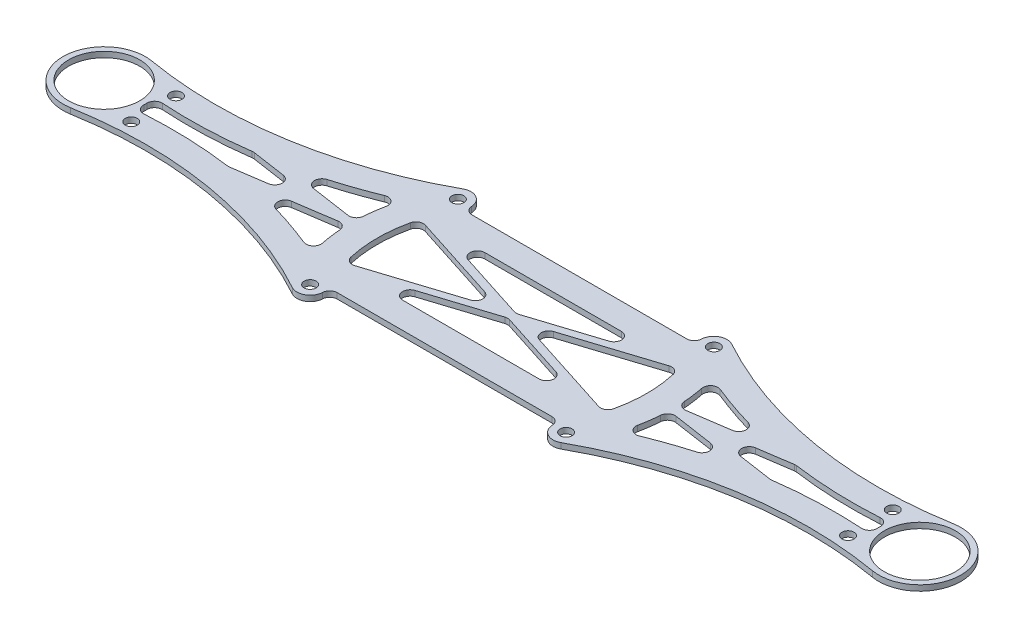
from build123d import *

# Parameters (mm, degrees)
SKETCH1_R                  = 3.5
BOSS_EXTRUDE1_DEPTH        = 0.75
F_3_2_3_2_DIAMETER_HOLE1_D = 3.2
SKETCH4_R                  = 9.5
CUT_EXTRUDE1_DEPTH         = 2.5
CUT_EXTRUDE4_DEPTH         = 2.5
FILLET1_R                  = 2


with BuildPart() as part:
    # Sketch1 → Boss-Extrude1 (new body, symmetric)
    with BuildSketch(Plane(origin=(0, 0, 0), x_dir=(1, 0, 0), z_dir=(0, 1, 0))):
        with BuildLine():
            ThreePointArc((-37.239092363, -21.5), (-43, 0), (-37.239092363, 21.5))
            ThreePointArc((-37.239092363, 21.5), (-36.658838331, 22.248681329), (-35.899079455, 22.81435343))
            ThreePointArc((-35.899079455, 22.81435343), (-70.492179883, 10.7556392), (-107.126701642, 10.839315166))
            ThreePointArc((-107.126701642, 10.839315166), (-120, 0), (-107.126701642, -10.839315166))
            ThreePointArc((-107.126701642, -10.839315166), (-70.492179883, -10.7556392), (-35.899079455, -22.81435343))
            ThreePointArc((-35.899079455, -22.81435343), (-36.658838331, -22.248681329), (-37.239092363, -21.5))
        make_face()
        with BuildLine():
            ThreePointArc((-31.176914536, -18), (-36, 0), (-31.176914536, 18))
            ThreePointArc((-31.176914536, 18), (-35.958003449, 16.718911087), (-37.239092363, 21.5))
            ThreePointArc((-37.239092363, 21.5), (-43, 0), (-37.239092363, -21.5))
            ThreePointArc((-37.239092363, -21.5), (-35.958003449, -16.718911087), (-31.176914536, -18))
        make_face()
        with Locations((-34.208003449, -19.75)):
            Circle(SKETCH1_R)
        with Locations((-34.208003449, 19.75)):
            Circle(SKETCH1_R)
        with BuildLine():
            ThreePointArc((31.176914536, 18), (36, 0), (31.176914536, -18))
            Line((31.176914536, -18), (-31.176914536, -18))
            ThreePointArc((-31.176914536, -18), (-36, 0), (-31.176914536, 18))
            Line((-31.176914536, 18), (31.176914536, 18))
        make_face()
        with Locations((34.208003449, 19.75)):
            Circle(SKETCH1_R)
        with BuildLine():
            ThreePointArc((37.708003449, 19.75), (35.113870107, 16.369259608), (31.176914536, 18))
            ThreePointArc((31.176914536, 18), (36, 0), (31.176914536, -18))
            ThreePointArc((31.176914536, -18), (35.113870107, -16.369259608), (37.708003449, -19.75))
            ThreePointArc((37.708003449, -19.75), (37.588743841, -20.655866658), (37.239092363, -21.5))
            ThreePointArc((37.239092363, -21.5), (43, 0), (37.239092363, 21.5))
            ThreePointArc((37.239092363, 21.5), (37.588743841, 20.655866658), (37.708003449, 19.75))
        make_face()
        with Locations((34.208003449, -19.75)):
            Circle(SKETCH1_R)
        with BuildLine():
            ThreePointArc((107.126701642, 10.839315166), (70.492179883, 10.7556392), (35.899079455, 22.81435343))
            ThreePointArc((35.899079455, 22.81435343), (36.658838331, 22.248681329), (37.239092363, 21.5))
            ThreePointArc((37.239092363, 21.5), (43, 0), (37.239092363, -21.5))
            ThreePointArc((37.239092363, -21.5), (36.658838331, -22.248681329), (35.899079455, -22.81435343))
            ThreePointArc((35.899079455, -22.81435343), (70.492179883, -10.7556392), (107.126701642, -10.839315166))
            ThreePointArc((107.126701642, -10.839315166), (120, 0), (107.126701642, 10.839315166))
        make_face()
    extrude(amount=BOSS_EXTRUDE1_DEPTH, both=True)

    # Ø3.2 (3.2) Diameter Hole1 (through all)
    with Locations(Plane(origin=(0, 0.75, 0), x_dir=(1, 0, 0), z_dir=(0, 1, 0))):
        with Locations((-34.208003449, 19.75), (-34.208003449, -19.75), (34.208003449, -19.75), (34.208003449, 19.75), (-95.790276336, 5.979398024), (-95.790276336, -5.979398024), (95.790276336, 5.979398024), (95.790276336, -5.979398024)):
            Hole(F_3_2_3_2_DIAMETER_HOLE1_D / 2)

    # Sketch4 → Cut-Extrude1 (cut, through all)
    with BuildSketch(Plane(origin=(0, 0.75, 0), x_dir=(1, 0, 0), z_dir=(0, 1, 0))):
        with Locations((-109, 0)):
            Circle(SKETCH4_R)
        with BuildLine():
            Line((-72.469338063, -3.369046694), (-49.802019621, 0))
            Line((-49.802019621, 0), (-72.469338063, 3.369046694))
            ThreePointArc((-72.469338063, 3.369046694), (-85.377857375, 2.290839769), (-98.326107181, 2.65857332))
            ThreePointArc((-98.326107181, 2.65857332), (-98, 0), (-98.326107181, -2.65857332))
            ThreePointArc((-98.326107181, -2.65857332), (-85.377857375, -2.290839769), (-72.469338063, -3.369046694))
        make_face()
        with BuildLine():
            Line((-66.096117167, 4.443764231), (-42.988154947, 1.009224591))
            ThreePointArc((-42.988154947, 1.009224591), (-42.467311238, 6.747405149), (-41.183985346, 12.36443897))
            ThreePointArc((-41.183985346, 12.36443897), (-53.416219701, 7.70010587), (-66.096117167, 4.443764231))
        make_face()
        with BuildLine():
            ThreePointArc((-41.183985346, -12.36443897), (-42.467311238, -6.747405149), (-42.988154947, -1.009224591))
            Line((-42.988154947, -1.009224591), (-66.096117167, -4.443764231))
            ThreePointArc((-66.096117167, -4.443764231), (-53.416219701, -7.70010587), (-41.183985346, -12.36443897))
        make_face()
        with BuildLine():
            Line((72.469338063, 3.369046694), (49.802019621, 0))
            Line((49.802019621, 0), (72.469338063, -3.369046694))
            ThreePointArc((72.469338063, -3.369046694), (85.377857375, -2.290839769), (98.326107181, -2.65857332))
            ThreePointArc((98.326107181, -2.65857332), (98, 0), (98.326107181, 2.65857332))
            ThreePointArc((98.326107181, 2.65857332), (85.377857375, 2.290839769), (72.469338063, 3.369046694))
        make_face()
        with BuildLine():
            ThreePointArc((41.183985346, 12.36443897), (42.467311238, 6.747405149), (42.988154947, 1.009224591))
            Line((42.988154947, 1.009224591), (66.096117167, 4.443764231))
            ThreePointArc((66.096117167, 4.443764231), (53.416219701, 7.70010587), (41.183985346, 12.36443897))
        make_face()
        with BuildLine():
            Line((66.096117167, -4.443764231), (42.988154947, -1.009224591))
            ThreePointArc((42.988154947, -1.009224591), (42.467311238, -6.747405149), (41.183985346, -12.36443897))
            ThreePointArc((41.183985346, -12.36443897), (53.416219701, -7.70010587), (66.096117167, -4.443764231))
        make_face()
        with Locations((109, 0)):
            Circle(SKETCH4_R)
    extrude(amount=-CUT_EXTRUDE1_DEPTH, mode=Mode.SUBTRACT)

    # Sketch5 → Cut-Extrude4 (cut, through all)
    with BuildSketch(Plane(origin=(0, 0.75, 0), x_dir=(1, 0, 0), z_dir=(0, 1, 0))):
        with BuildLine():
            Line((-3.272727273, 0), (-34.570601363, 10.043581104))
            ThreePointArc((-34.570601363, 10.043581104), (-36, 0), (-34.570601363, -10.043581104))
            Line((-34.570601363, -10.043581104), (-3.272727273, 0))
        make_face()
        with BuildLine():
            Line((34.570601363, 10.043581104), (3.272727273, 0))
            Line((3.272727273, 0), (34.570601363, -10.043581104))
            ThreePointArc((34.570601363, -10.043581104), (36, 0), (34.570601363, 10.043581104))
        make_face()
        Polygon((31.005545729, 11), (-31.005545729, 11), (0, 1.050227939), align=None)
        Polygon((31.005545729, -11), (0, -1.050227939), (-31.005545729, -11), align=None)
    extrude(amount=-CUT_EXTRUDE4_DEPTH, mode=Mode.SUBTRACT)

    # Fillet1
    fillet1_edges = [part.edges().sort_by_distance(p)[0] for p in [
        (-72.469338063, 0, 3.369046694),
        (-98.326107181, 0, 2.65857332),
        (-98.326107181, 0, -2.65857332),
        (-72.469338063, 0, -3.369046694),
        (-49.802019621, 0, 0),
        (-66.096117167, 0, -4.443764231),
        (-41.183985346, 0, -12.36443897),
        (-42.988154947, 0, -1.009224591),
        (-41.183985346, 0, 12.36443897),
        (-66.096117167, 0, 4.443764231),
        (-42.988154947, 0, 1.009224591),
        (98.326107181, 0, -2.65857332),
        (98.326107181, 0, 2.65857332),
        (72.469338063, 0, 3.369046694),
        (49.802019621, 0, 0),
        (72.469338063, 0, -3.369046694),
        (41.183985346, 0, -12.36443897),
        (66.096117167, 0, -4.443764231),
        (42.988154947, 0, -1.009224591),
        (42.988154947, 0, 1.009224591),
        (66.096117167, 0, 4.443764231),
        (41.183985346, 0, 12.36443897),
        (-34.570601363, 0, -10.043581104),
        (-3.272727273, 0, 0),
        (-34.570601363, 0, 10.043581104),
        (34.570601363, 0, 10.043581104),
        (3.272727273, 0, 0),
        (34.570601363, 0, -10.043581104),
        (31.176914536, 0, 18),
        (-31.176914536, 0, 18),
        (0, 0, -1.050227939),
        (-31.005545729, 0, -11),
        (31.005545729, 0, -11),
        (-31.176914536, 0, -18),
        (31.176914536, 0, -18),
        (-31.005545729, 0, 11),
        (0, 0, 1.050227939),
        (31.005545729, 0, 11),
    ]]
    fillet(fillet1_edges, radius=FILLET1_R)


solid = part.part
